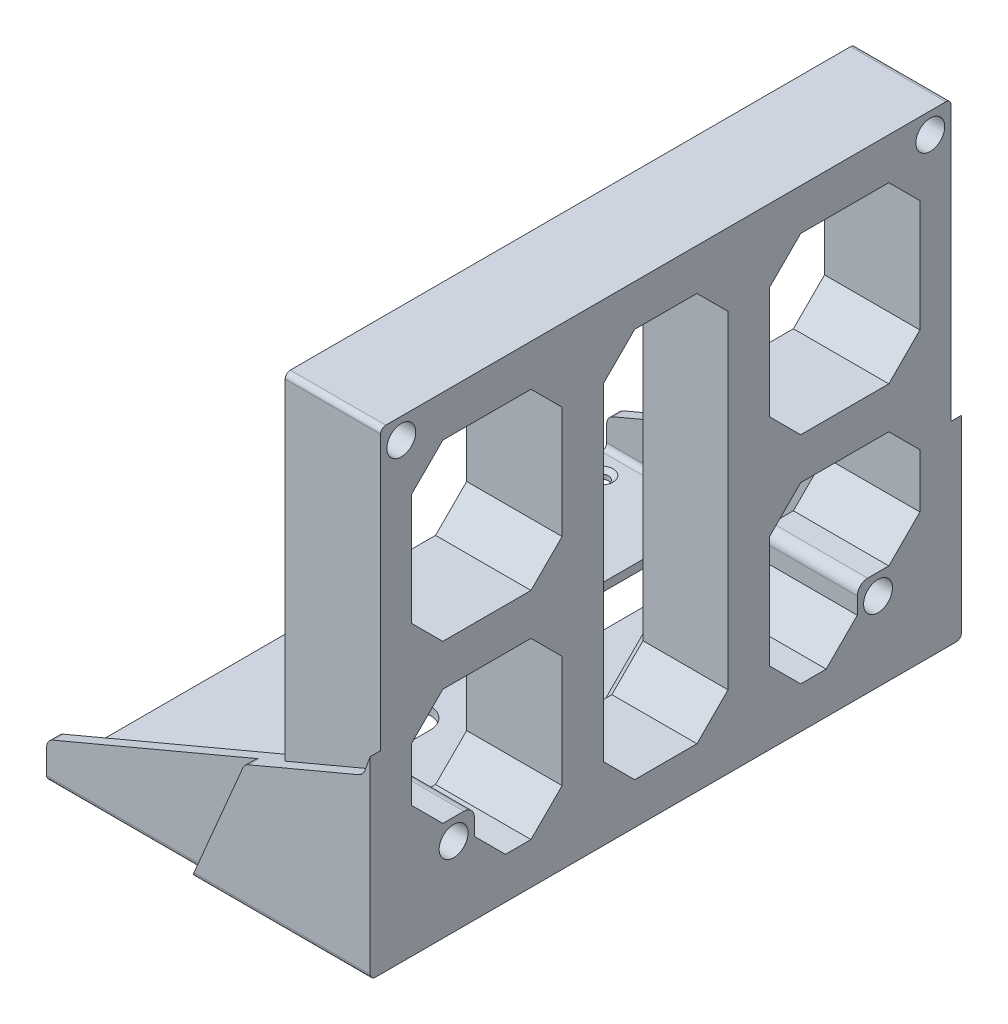
from build123d import *

# Parameters (mm, degrees)
SKETCH2_W                                 = 180.975
SKETCH2_H                                 = 144.78
BOSS_EXTRUDE1_DEPTH                       = 149.225
BOSS_EXTRUDE2_DEPTH                       = 3.175
BOSS_EXTRUDE3_DEPTH                       = 3.175
BOSS_EXTRUDE4_DEPTH                       = 3.175
CUT_EXTRUDE1_DEPTH                        = 3.175
SKETCH7_W                                 = 73.025
SKETCH7_H                                 = 171.45
BOSS_EXTRUDE6_DEPTH                       = 2.54
FILLET1_R                                 = 1.5875
SKETCH10_W                                = 155.575
SKETCH10_H                                = 119.38
CUT_EXTRUDE2_DEPTH                        = 223.25
FILLET3_R                                 = 3.175
CHAMFER1_SIZE                             = 6.35
FILLET4_R                                 = 6.35
SKETCH11_W                                = 180.975
SKETCH11_H                                = 144.78
CUT_EXTRUDE3_DEPTH                        = 82.55
FILLET5_R                                 = 1.5875
CUT_EXTRUDE4_REACH                        = 146.78
BOSS_EXTRUDE7_DEPTH                       = 66.675
BOSS_EXTRUDE8_DEPTH                       = 9.525
S_0_348_DIAMETER_HOLE1_D                  = 8.8392
CSK_FOR_6_FLAT_HEAD_MACHINE_SCREW_2_COUNT = 2
CSK_FOR_6_FLAT_HEAD_MACHINE_SCREW_2_PITCH = 46.0375
CSK_FOR_6_FLAT_HEAD_MACHINE_SCREW_3_COUNT = 2
CSK_FOR_6_FLAT_HEAD_MACHINE_SCREW_3_PITCH = 159.201794608
CSK_FOR_6_FLAT_HEAD_MACHINE_SCREW_4_COUNT = 2
CSK_FOR_6_FLAT_HEAD_MACHINE_SCREW_4_PITCH = 152.4
CSK_FOR_6_FLAT_HEAD_MACHINE_SCREW_5_COUNT = 2
CSK_FOR_6_FLAT_HEAD_MACHINE_SCREW_5_PITCH = 79.600897304
F_1_4_CLEARANCE_HOLE1_D                   = 7.14248
RELIEF_FOR_MIP_FACE_SUPPORT_DEPTH         = 37.465
SKETCH23_W                                = 6.35
SKETCH23_H                                = 119.38
SKETCH23_W_2                              = 155.575
SKETCH23_H_2                              = 6.35
EXTRUDE_THIN1_DEPTH                       = 29.21
FILLET6_R                                 = 6.35
CUT_EXTRUDE5_DEPTH                        = 29.21
SKETCH25_W                                = 12.7
SKETCH25_H                                = 119.38
SKETCH25_W_2                              = 52.3875
SKETCH25_H_2                              = 12.7
EXTRUDE_THIN2_DEPTH                       = 29.21
CHAMFER2_SIZE                             = 9.525
CHAMFER3_SIZE                             = 3.175


with BuildPart() as part:
    # Sketch2 → Boss-Extrude1 (new body)
    with BuildSketch(Plane(origin=(149.225, 0, 0), x_dir=(0, 0, -1), z_dir=(1, 0, 0))):
        with Locations((84.0105, -72.39)):
            Rectangle(SKETCH2_W, SKETCH2_H)
    extrude(amount=-BOSS_EXTRUDE1_DEPTH)

    # Sketch3_3 → Boss-Extrude2 (add)
    with BuildSketch(Plane.XY.offset(6.477)):
        Polygon((-9.271174074, -106.782867284), (-25.4, -144.78), (149.225, -144.78), (149.225, 0), (60.325, 0), (27.03103123, -91.474427399), align=None)
    extrude(amount=-BOSS_EXTRUDE2_DEPTH)



with BuildPart() as body_2:
    # Sketch4 → Boss-Extrude3 (new body)
    with BuildSketch(Plane.XY.offset(0.127)):
        Polygon((-73.025, -133.667504276), (-73.025, -144.78), (-25.4, -144.78), (-9.271174074, -106.782867284), align=None)
    extrude(amount=BOSS_EXTRUDE3_DEPTH)


with BuildPart() as part_1:
    add(part.part)

    add(body_2.part)  # Boss-Extrude4 merges body 2
    # Sketch5 → Boss-Extrude4 (add)
    with BuildSketch(Plane(origin=(0, 0, 3.302), x_dir=(-1, 0, 0), z_dir=(0, 0, -1))):
        Polygon((0, -102.873264278), (0, -144.78), (25.4, -144.78), (9.271174074, -106.782867284), align=None)
    extrude(amount=BOSS_EXTRUDE4_DEPTH)

    # Mirror5: part across plane


with BuildPart() as part_2:
    add(part_1.part)
    add(part_1.part.mirror(Plane.XY.offset(-84.0105)))

    # Sketch3 → Cut-Extrude1 (cut)
    with BuildSketch(Plane.XY.offset(6.477)):
        Polygon((27.03103123, -91.474427399), (60.325, 0), (0, 0), (0, -102.873264278), align=None)
    cut_extrude1 = extrude(amount=-CUT_EXTRUDE1_DEPTH, mode=Mode.SUBTRACT)

    # Mirror6: Cut-Extrude1 across plane
    add(cut_extrude1.mirror(Plane.XY.offset(-84.0105)), mode=Mode.SUBTRACT)

    # Sketch7 → Boss-Extrude6 (add)
    with BuildSketch(Plane.XZ.offset(144.78)):
        with Locations((-36.5125, -85.598)):
            Rectangle(SKETCH7_W, SKETCH7_H)
    extrude(amount=-BOSS_EXTRUDE6_DEPTH)

    # Fillet1
    fillet1_edges = [part_2.edges().sort_by_distance(p)[0] for p in [
        (30.1625, 0, 3.302),
        (30.1625, 0, -171.323),
    ]]
    fillet(fillet1_edges, radius=FILLET1_R)

    # Sketch10 → Cut-Extrude2 (cut, through all)
    with BuildSketch(Plane(origin=(149.225, 0, 0), x_dir=(0, 0, -1), z_dir=(1, 0, 0))):
        with Locations((84.0105, -72.39)):
            Rectangle(SKETCH10_W, SKETCH10_H)
    extrude(amount=-CUT_EXTRUDE2_DEPTH, mode=Mode.SUBTRACT)

    # Fillet3
    fillet3_edges = [part_2.edges().sort_by_distance(p)[0] for p in [
        (27.03103123, -91.474427399, 4.8895),
        (27.03103123, -91.474427399, -172.9105),
        (-9.271174074, -106.782867284, 4.8895),
        (-73.025, -133.667504276, 1.7145),
        (-73.025, -133.667504276, -169.7355),
        (-9.271174074, -106.782867284, -172.9105),
    ]]
    fillet(fillet3_edges, radius=FILLET3_R)

    # Chamfer1
    chamfer1_edges = [part_2.edges().sort_by_distance(p)[0] for p in [
        (74.6125, -12.7, -161.798),
        (74.6125, -132.08, -161.798),
        (74.6125, -132.08, -6.223),
        (74.6125, -12.7, -6.223),
    ]]
    chamfer(chamfer1_edges, length=CHAMFER1_SIZE)

    # Fillet4
    fillet4_edges = [part_2.edges().sort_by_distance(p)[0] for p in [
        (74.6125, -125.73, -6.223),
        (74.6125, -19.05, -6.223),
        (74.6125, -12.7, -155.448),
        (74.6125, -12.7, -12.573),
        (74.6125, -132.08, -155.448),
        (74.6125, -132.08, -12.573),
        (74.6125, -19.05, -161.798),
        (74.6125, -125.73, -161.798),
    ]]
    fillet(fillet4_edges, radius=FILLET4_R)

    # Sketch11 → Cut-Extrude3 (cut)
    with BuildSketch(Plane(origin=(149.225, 0, 0), x_dir=(0, 0, -1), z_dir=(1, 0, 0))):
        with Locations((84.0105, -72.39)):
            Rectangle(SKETCH11_W, SKETCH11_H)
    extrude(amount=-CUT_EXTRUDE3_DEPTH, mode=Mode.SUBTRACT)

    # Fillet5
    fillet5_edges = [part_2.edges().sort_by_distance(p)[0] for p in [
        (20.6375, -144.78, 6.477),
        (20.6375, -144.78, -174.498),
        (-36.5125, -142.24, 0.127),
        (-36.5125, -142.24, -168.148),
        (-49.2125, -144.78, 3.302),
        (-49.2125, -144.78, -171.323),
    ]]
    fillet(fillet5_edges, radius=FILLET5_R)

    # Sketch12 → Cut-Extrude4 (cut, up to next)
    with BuildSketch(Plane.XZ.offset(144.78), mode=Mode.PRIVATE) as cut_extrude4_sk1:
        with BuildLine():
            Line((-38.1, -101.473), (-38.1, -152.273))
            ThreePointArc((-38.1, -152.273), (-31.75, -158.623), (-25.4, -152.273))
            Line((-25.4, -152.273), (-25.4, -101.473))
            ThreePointArc((-25.4, -101.473), (-31.75, -95.123), (-38.1, -101.473))
        make_face()
    cut_extrude4_tool1 = extrude(cut_extrude4_sk1.sketch, amount=-CUT_EXTRUDE4_REACH, mode=Mode.PRIVATE) & part_2.part
    add(cut_extrude4_tool1.solids().sort_by_distance((-31.75, -144.78, -126.873))[0], mode=Mode.SUBTRACT)
    # Sketch12 → Cut-Extrude4 (cut, up to next)
    with BuildSketch(Plane.XZ.offset(144.78), mode=Mode.PRIVATE) as cut_extrude4_sk2:
        with BuildLine():
            Line((-25.4, -66.548), (-25.4, -15.748))
            ThreePointArc((-25.4, -15.748), (-31.75, -9.398), (-38.1, -15.748))
            Line((-38.1, -15.748), (-38.1, -66.548))
            ThreePointArc((-38.1, -66.548), (-31.75, -72.898), (-25.4, -66.548))
        make_face()
    cut_extrude4_tool2 = extrude(cut_extrude4_sk2.sketch, amount=-CUT_EXTRUDE4_REACH, mode=Mode.PRIVATE) & part_2.part
    add(cut_extrude4_tool2.solids().sort_by_distance((-31.75, -144.78, -41.148))[0], mode=Mode.SUBTRACT)

    # Sketch18 → Boss-Extrude7 (add)
    with BuildSketch(Plane(origin=(66.675, 0, 0), x_dir=(0, 0, -1), z_dir=(1, 0, 0))):
        with BuildLine():
            Line((15.203256121, -132.08), (25.4, -132.08))
            Line((25.4, -132.08), (25.4, -117.475))
            ThreePointArc((25.4, -117.475), (24.47006403, -115.22993597), (22.225, -114.3))
            Line((22.225, -114.3), (6.223, -114.3))
            Line((6.223, -114.3), (6.223, -123.099743879))
            ThreePointArc((6.223, -123.099743879), (6.706364969, -125.529783674), (8.082871939, -127.589871939))
            Line((8.082871939, -127.589871939), (10.713128061, -130.220128061))
            ThreePointArc((10.713128061, -130.220128061), (12.773216326, -131.596635031), (15.203256121, -132.08))
        make_face()
        with BuildLine():
            Line((161.798, -123.099743879), (161.798, -114.3))
            Line((161.798, -114.3), (145.796, -114.3))
            ThreePointArc((145.796, -114.3), (143.55093597, -115.22993597), (142.621, -117.475))
            Line((142.621, -117.475), (142.621, -132.08))
            Line((142.621, -132.08), (152.817743879, -132.08))
            ThreePointArc((152.817743879, -132.08), (155.247783674, -131.596635031), (157.307871939, -130.220128061))
            Line((157.307871939, -130.220128061), (159.938128061, -127.589871939))
            ThreePointArc((159.938128061, -127.589871939), (161.314635031, -125.529783674), (161.798, -123.099743879))
        make_face()
    extrude(amount=-BOSS_EXTRUDE7_DEPTH)

    # Sketch18_3 → Boss-Extrude8 (add)
    with BuildSketch(Plane(origin=(66.675, 0, 0), x_dir=(0, 0, -1), z_dir=(1, 0, 0))):
        with BuildLine():
            Line((145.796, -30.48), (161.798, -30.48))
            Line((161.798, -30.48), (161.798, -21.680256121))
            ThreePointArc((161.798, -21.680256121), (161.314635031, -19.250216326), (159.938128061, -17.190128061))
            Line((159.938128061, -17.190128061), (157.307871939, -14.559871939))
            ThreePointArc((157.307871939, -14.559871939), (155.247783674, -13.183364969), (152.817743879, -12.7))
            Line((152.817743879, -12.7), (142.621, -12.7))
            Line((142.621, -12.7), (142.621, -27.305))
            ThreePointArc((142.621, -27.305), (143.55093597, -29.55006403), (145.796, -30.48))
        make_face()
        with BuildLine():
            Line((25.4, -27.305), (25.4, -12.7))
            Line((25.4, -12.7), (15.203256121, -12.7))
            ThreePointArc((15.203256121, -12.7), (12.773216326, -13.183364969), (10.713128061, -14.559871939))
            Line((10.713128061, -14.559871939), (8.082871939, -17.190128061))
            ThreePointArc((8.082871939, -17.190128061), (6.706364969, -19.250216326), (6.223, -21.680256121))
            Line((6.223, -21.680256121), (6.223, -30.48))
            Line((6.223, -30.48), (22.225, -30.48))
            ThreePointArc((22.225, -30.48), (24.47006403, -29.55006403), (25.4, -27.305))
        make_face()
    extrude(amount=-BOSS_EXTRUDE8_DEPTH)

    # S _0.348_ Diameter Hole1 (through all)
    with Locations(Plane.ZY):
        with Locations((-164.973, -6.35), (-3.048, -6.35), (-19.05, -120.65), (-148.971, -120.65)):
            Hole(S_0_348_DIAMETER_HOLE1_D / 2)

    # Sketch17 → CSK for _6 Flat Head Machine Screw _100 (revolve, cut)
    with BuildSketch(Plane(origin=(-20.6375, -142.24, -7.8105), x_dir=(0, 0, 1), z_dir=(1, 0, 0))):
        Polygon((0, 0), (0, 2.54), (2.15265, 2.54), (2.15265, 1.166893902), (3.5433, 0), align=None)
    csk_for_6_flat_head_machine_screw_100 = revolve(axis=Axis((-20.6375, -135.89, -7.8105), (0, -1, 0)), mode=Mode.SUBTRACT)

    # CSK for _6 Flat Head Machine Screw _ 2: CSK for _6 Flat Head Machine Screw _100 ×2
    with Locations(*[(-i * CSK_FOR_6_FLAT_HEAD_MACHINE_SCREW_2_PITCH, 0, 0) for i in range(1, CSK_FOR_6_FLAT_HEAD_MACHINE_SCREW_2_COUNT)]):
        add(csk_for_6_flat_head_machine_screw_100, mode=Mode.SUBTRACT)

    # CSK for _6 Flat Head Machine Screw _ 3: CSK for _6 Flat Head Machine Screw _100 ×2
    with Locations(*[Vector(-0.289177017, 0, -0.957275641) * (i * CSK_FOR_6_FLAT_HEAD_MACHINE_SCREW_3_PITCH) for i in range(1, CSK_FOR_6_FLAT_HEAD_MACHINE_SCREW_3_COUNT)]):
        add(csk_for_6_flat_head_machine_screw_100, mode=Mode.SUBTRACT)

    # CSK for _6 Flat Head Machine Screw _ 4: CSK for _6 Flat Head Machine Screw _100 ×2
    with Locations(*[(0, 0, -i * CSK_FOR_6_FLAT_HEAD_MACHINE_SCREW_4_PITCH) for i in range(1, CSK_FOR_6_FLAT_HEAD_MACHINE_SCREW_4_COUNT)]):
        add(csk_for_6_flat_head_machine_screw_100, mode=Mode.SUBTRACT)

    # CSK for _6 Flat Head Machine Screw _ 5: CSK for _6 Flat Head Machine Screw _100 ×2
    with Locations(*[Vector(-0.289177017, 0, -0.957275641) * (i * CSK_FOR_6_FLAT_HEAD_MACHINE_SCREW_5_PITCH) for i in range(1, CSK_FOR_6_FLAT_HEAD_MACHINE_SCREW_5_COUNT)]):
        add(csk_for_6_flat_head_machine_screw_100, mode=Mode.SUBTRACT)

    # 1_4 Clearance Hole1 (through all)
    with Locations(Plane.ZY.offset(-57.15)):
        with Locations((-19.05, -24.13), (-148.971, -24.13)):
            Hole(F_1_4_CLEARANCE_HOLE1_D / 2)

    # Sketch22 → Relief for MIP face support (cut)
    with BuildSketch(Plane(origin=(66.675, 0, 0), x_dir=(0, 0, -1), z_dir=(1, 0, 0))):
        with BuildLine():
            Line((-4.8895, -144.78), (172.9105, -144.78))
            ThreePointArc((172.9105, -144.78), (174.033032015, -144.315032015), (174.498, -143.1925))
            Line((174.498, -143.1925), (174.498, 0))
            Line((174.498, 0), (-6.477, 0))
            Line((-6.477, 0), (-6.477, -143.1925))
            ThreePointArc((-6.477, -143.1925), (-6.012032015, -144.315032015), (-4.8895, -144.78))
        make_face()
    extrude(amount=-RELIEF_FOR_MIP_FACE_SUPPORT_DEPTH, mode=Mode.SUBTRACT)

    # Sketch23 → Extrude-Thin1 (add)
    with BuildSketch(Plane(origin=(29.21, 0, 0), x_dir=(0, 0, -1), z_dir=(1, 0, 0))):
        with Locations((84.0105, -72.39)):
            Rectangle(SKETCH23_W, SKETCH23_H)
        with Locations((84.0105, -67.990128061)):
            Rectangle(SKETCH23_W_2, SKETCH23_H_2)
    extrude(amount=-EXTRUDE_THIN1_DEPTH)

    # Fillet6
    fillet6_edges = [part_2.edges().sort_by_distance(p)[0] for p in [
        (14.605, -132.08, -80.8355),
        (14.605, -71.165128061, -87.1855),
        (14.605, -12.7, -80.8355),
        (14.605, -64.815128061, -80.8355),
        (14.605, -132.08, -87.1855),
        (14.605, -12.7, -87.1855),
        (14.605, -64.815128061, -161.798),
        (14.605, -64.815128061, -87.1855),
        (14.605, -71.165128061, -161.798),
        (14.605, -71.165128061, -80.8355),
        (14.605, -64.815128061, -6.223),
        (14.605, -71.165128061, -6.223),
    ]]
    fillet(fillet6_edges, radius=FILLET6_R)

    # Sketch24 → Cut-Extrude5 (cut)
    with BuildSketch(Plane(origin=(29.21, 0, 0), x_dir=(0, 0, -1), z_dir=(1, 0, 0))):
        Polygon((25.4, -132.08), (25.4, -114.3), (6.223, -114.3), (6.223, -12.7), (161.798, -12.7), (161.798, -114.3), (142.621, -114.3), (142.621, -132.08), align=None)
    extrude(amount=-CUT_EXTRUDE5_DEPTH, mode=Mode.SUBTRACT)

    # Sketch25 → Extrude-Thin2 (add)
    with BuildSketch(Plane(origin=(29.21, 0, 0), x_dir=(0, 0, -1), z_dir=(1, 0, 0))):
        with Locations((58.6105, -72.39)):
            Rectangle(SKETCH25_W, SKETCH25_H)
        with Locations((32.41675, -72.39)):
            Rectangle(SKETCH25_W_2, SKETCH25_H_2)
        with Locations((135.60425, -72.39)):
            Rectangle(SKETCH25_W_2, SKETCH25_H_2)
        with Locations((109.4105, -72.39)):
            Rectangle(SKETCH25_W, SKETCH25_H)
    extrude(amount=-EXTRUDE_THIN2_DEPTH)

    # Chamfer2
    chamfer2_edges = [part_2.edges().sort_by_distance(p)[0] for p in [
        (14.605, -114.3, -6.223),
        (14.605, -132.08, -25.4),
        (14.605, -114.3, -161.798),
        (14.605, -132.08, -142.621),
        (14.605, -12.7, -6.223),
        (14.605, -12.7, -161.798),
        (14.605, -132.08, -52.2605),
        (14.605, -12.7, -52.2605),
        (14.605, -66.04, -52.2605),
        (14.605, -132.08, -64.9605),
        (14.605, -12.7, -64.9605),
        (14.605, -78.74, -52.2605),
        (14.605, -66.04, -6.223),
        (14.605, -78.74, -6.223),
        (14.605, -66.04, -161.798),
        (14.605, -66.04, -115.7605),
        (14.605, -78.74, -161.798),
        (14.605, -12.7, -115.7605),
        (14.605, -12.7, -103.0605),
        (14.605, -132.08, -103.0605),
        (14.605, -132.08, -115.7605),
        (14.605, -78.74, -115.7605),
    ]]
    chamfer(chamfer2_edges, length=CHAMFER2_SIZE)

    # Chamfer3
    chamfer3_edges = [part_2.edges().sort_by_distance(p)[0] for p in [
        (0, -17.4625, -98.298),
        (0, -17.4625, -69.723),
        (0, -127.3175, -69.723),
        (0, -127.3175, -98.298),
        (0, -12.7, -84.0105),
        (0, -72.39, -103.0605),
        (0, -72.39, -64.9605),
        (0, -132.08, -84.0105),
    ]]
    chamfer(chamfer3_edges, length=CHAMFER3_SIZE)


solid = part_2.part
